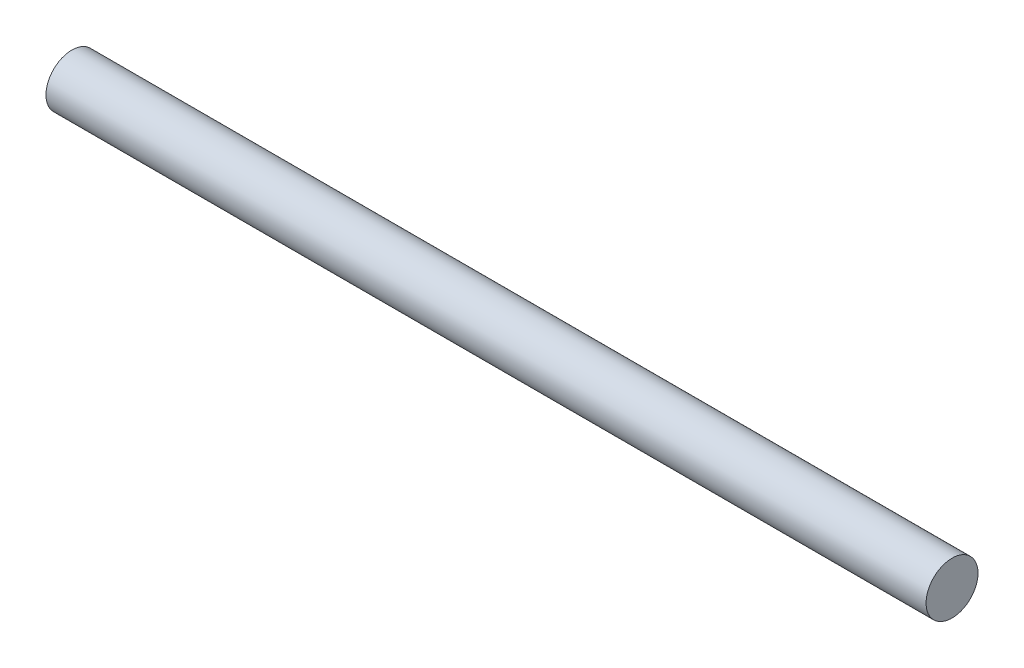
from build123d import *

# Parameters (mm, degrees)
SKETCH1_R           = 1.475
BOSS_EXTRUDE1_DEPTH = 50


with BuildPart() as part:
    # Sketch1 → Boss-Extrude1 (new body)
    with BuildSketch(Plane(origin=(0, 0, 0), x_dir=(0, 0, -1), z_dir=(1, 0, 0))):
        Circle(SKETCH1_R)
    extrude(amount=BOSS_EXTRUDE1_DEPTH)


solid = part.part
